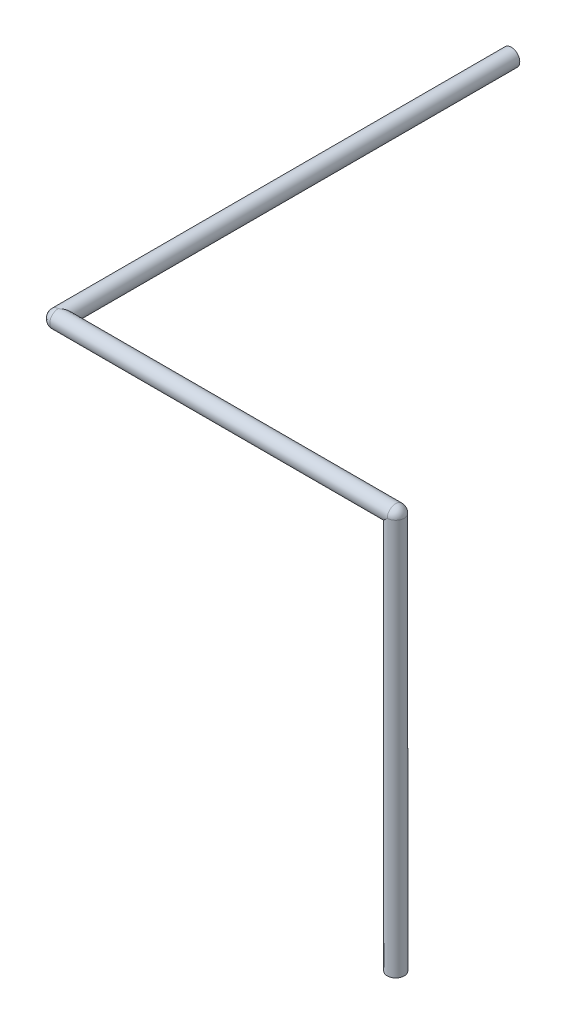
from build123d import *

# Parameters (mm, degrees)
SKETCH4_R           = 1.905
BOSS_EXTRUDE1_DEPTH = 101.6
SKETCH5_R           = 1.905
BOSS_EXTRUDE2_DEPTH = 75.692
SKETCH7_R           = 1.905
BOSS_EXTRUDE3_DEPTH = 88.9


with BuildPart() as part:
    # Sketch4 → Boss-Extrude1 (new body)
    with BuildSketch(Plane.XY):
        Circle(SKETCH4_R)
    extrude(amount=BOSS_EXTRUDE1_DEPTH)

    # Sketch5 → Boss-Extrude2 (add)
    with BuildSketch(Plane(origin=(0, 0, 0), x_dir=(0, 0, -1), z_dir=(1, 0, 0))):
        with Locations((-101.6, 0)):
            Circle(SKETCH5_R)
    extrude(amount=BOSS_EXTRUDE2_DEPTH)

    # Sketch6 → Revolve1 (revolve)
    with BuildSketch(Plane.ZY):
        with BuildLine():
            Line((101.6, 1.905), (101.6, -1.905))
            ThreePointArc((101.6, -1.905), (103.505, 0), (101.6, 1.905))
        make_face()
    revolve(axis=Axis((0, 1.905, 101.6), (0, -1, 0)))

    # Sketch7 → Boss-Extrude3 (add)
    with BuildSketch(Plane(origin=(0, 0, 0), x_dir=(1, 0, 0), z_dir=(0, 1, 0))):
        with Locations((75.692, -101.6)):
            Circle(SKETCH7_R)
    extrude(amount=-BOSS_EXTRUDE3_DEPTH)

    # Sketch8 → Revolve2 (revolve)
    with BuildSketch(Plane(origin=(0, 0, 0), x_dir=(1, 0, 0), z_dir=(0, 1, 0))):
        with BuildLine():
            Line((75.692, -99.695), (75.692, -103.505))
            ThreePointArc((75.692, -103.505), (77.597, -101.6), (75.692, -99.695))
        make_face()
    revolve(axis=Axis((75.692, 0, 99.695), (0, 0, 1)))


solid = part.part
